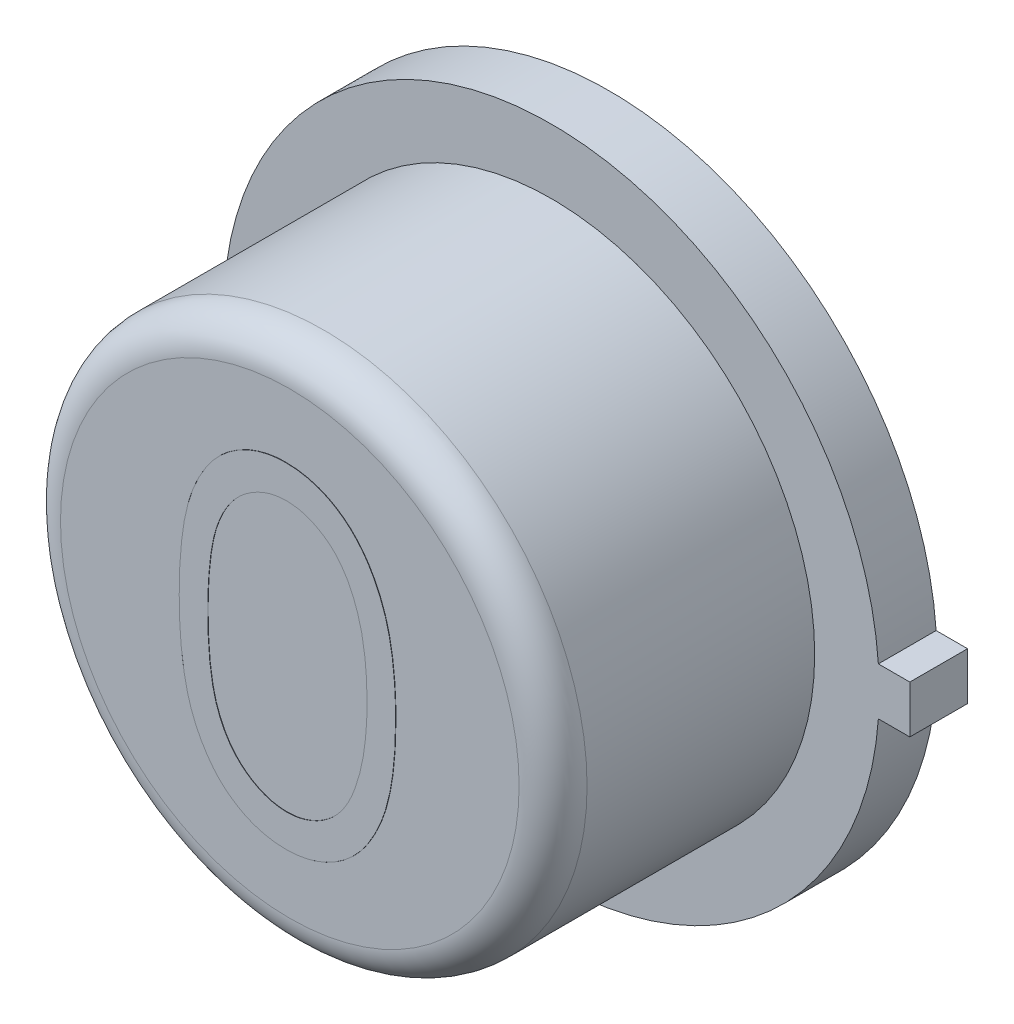
from build123d import *

# Parameters (mm, degrees)
BOSS_EXTRUDE1_DEPTH = 0.4318
SKETCH2_R           = 1.9685
BOSS_EXTRUDE2_DEPTH = 1.9558
SKETCH3_R           = 1.757566481
BOSS_EXTRUDE3_DEPTH = 0.00254
FILLET1_R           = 0.254
BOSS_EXTRUDE6_DEPTH = 0.00254


with BuildPart() as part:
    # Sketch1 → Boss-Extrude1 (new body)
    with BuildSketch(Plane.XY):
        with BuildLine():
            Line((2.6797, 0.1778), (2.4511, 0.1778))
            Line((2.4511, 0.1778), (2.44464279, 0.1778))
            ThreePointArc((2.44464279, 0.1778), (-2.4511, 0), (2.44464279, -0.1778))
            Line((2.44464279, -0.1778), (2.4511, -0.1778))
            Line((2.4511, -0.1778), (2.6797, -0.1778))
            Line((2.6797, -0.1778), (2.6797, 0.1778))
        make_face()
    extrude(amount=BOSS_EXTRUDE1_DEPTH)

    # Sketch2 → Boss-Extrude2 (add)
    with BuildSketch(Plane.XY.offset(0.4318)):
        Circle(SKETCH2_R)
    extrude(amount=BOSS_EXTRUDE2_DEPTH)

    # Sketch3 → Boss-Extrude3 (add)
    with BuildSketch(Plane(origin=(0, 0, 0), x_dir=(-1, 0, 0), z_dir=(0, 0, -1))):
        Circle(SKETCH3_R)
    extrude(amount=BOSS_EXTRUDE3_DEPTH)

    # Fillet1
    fillet1_edges = [part.edges().sort_by_distance(p)[0] for p in [
        (-1.9685, 0, 2.3876),
    ]]
    fillet(fillet1_edges, radius=FILLET1_R)

    # Sketch4 → Boss-Extrude6 (add)
    with BuildSketch(Plane.XY.offset(2.3876)):
        with BuildLine():
            add(Edge.make_bspline(
                [(-0.824278846, -0.028470233), (-0.824055677, 0.009696025), (-0.823622167, 0.083834532), (-0.818799509, 0.191864798), (-0.810788071, 0.293210994), (-0.799808894, 0.387877973), (-0.786448054, 0.475890174), (-0.76861216, 0.557012392), (-0.748328807, 0.631620089), (-0.724820804, 0.699956554), (-0.698295183, 0.762942456), (-0.66942473, 0.821742459), (-0.637063683, 0.876267595), (-0.603061533, 0.927388127), (-0.566041892, 0.974267248), (-0.52705825, 1.017566988), (-0.484589081, 1.056286624), (-0.44007807, 1.091560626), (-0.393122225, 1.122482499), (-0.345059983, 1.149719058), (-0.295560527, 1.172987182), (-0.244488713, 1.191282282), (-0.19230358, 1.206393591), (-0.138822701, 1.2167275), (-0.083957773, 1.22322961), (-0.046924957, 1.223851231), (-0.02814378, 1.224166485)],
                knots=[0, 0, 0, 0, 0.000114492, 0.000222403, 0.000324329, 0.000419413, 0.000508267, 0.000591258, 0.000668447, 0.000740102, 0.000807875, 0.000873367, 0.000936443, 0.000997963, 0.001057413, 0.001115492, 0.001172544, 0.00122961, 0.001285706, 0.001341027, 0.001395232, 0.001449558, 0.001503614, 0.00155806, 0.001612792, 0.001669112, 0.001669112, 0.001669112, 0.001669112], degree=3))
            add(Edge.make_bspline(
                [(-0.02814378, 1.224166485), (-0.009205713, 1.223834597), (0.028456143, 1.223174575), (0.084136826, 1.216830964), (0.138531164, 1.206305075), (0.191407254, 1.191390983), (0.243199433, 1.17288821), (0.293502596, 1.149696797), (0.342629199, 1.122700996), (0.389798556, 1.090980108), (0.435528499, 1.055613595), (0.478695774, 1.015633994), (0.519304309, 0.971444988), (0.557863758, 0.923519363), (0.593280156, 0.870937904), (0.627007794, 0.814615143), (0.657196626, 0.753566108), (0.686271467, 0.688809397), (0.711367792, 0.618553229), (0.73400072, 0.543193633), (0.752288018, 0.461840481), (0.76752072, 0.374920607), (0.779321443, 0.282114802), (0.787916152, 0.183622005), (0.792456233, 0.079377418), (0.793311238, 0.008104667), (0.79375, -0.028470233)],
                knots=[0, 0, 0, 0, 5.6797e-05, 0.000112951, 0.000167865, 0.00022284, 0.000277613, 0.000332685, 0.000388839, 0.000445596, 0.000503038, 0.000562112, 0.000621861, 0.000682948, 0.000746456, 0.000811902, 0.00087974, 0.000950647, 0.001024738, 0.00110337, 0.001186569, 0.001274717, 0.001368023, 0.001467137, 0.001571235, 0.001680965, 0.001680965, 0.001680965, 0.001680965], degree=3))
            add(Edge.make_bspline(
                [(0.79375, -0.028470233), (0.79330669, -0.064885606), (0.792442918, -0.135839476), (0.787967048, -0.239615014), (0.779150551, -0.337585112), (0.768121969, -0.42998473), (0.752847296, -0.516429288), (0.734065924, -0.597217922), (0.713212758, -0.672699514), (0.687471586, -0.742255698), (0.659297513, -0.806856781), (0.628643889, -0.867182109), (0.595803168, -0.92376489), (0.560024039, -0.976152218), (0.521887699, -1.024715197), (0.480577918, -1.068596615), (0.437259181, -1.108853805), (0.391394662, -1.144675715), (0.34348966, -1.176029841), (0.294531788, -1.204069979), (0.243652379, -1.22668008), (0.192004459, -1.246094099), (0.138849268, -1.260926192), (0.084253062, -1.271181798), (0.028493552, -1.27837443), (-0.009199299, -1.278923125), (-0.02814378, -1.279198899)],
                knots=[0, 0, 0, 0, 0.000109253, 0.000212874, 0.000311514, 0.000404286, 0.000491965, 0.000574698, 0.000653064, 0.000726706, 0.000796984, 0.000864397, 0.000929602, 0.000993109, 0.00105457, 0.001114643, 0.001173717, 0.001231829, 0.001288983, 0.00134537, 0.001400876, 0.001455813, 0.001510787, 0.00156617, 0.001622379, 0.001679176, 0.001679176, 0.001679176, 0.001679176], degree=3))
            add(Edge.make_bspline(
                [(-0.02814378, -1.279198899), (-0.046924436, -1.278881611), (-0.083956224, -1.27825598), (-0.138828678, -1.271783245), (-0.192088698, -1.26137684), (-0.2439991, -1.246805901), (-0.294826211, -1.22897045), (-0.343877435, -1.205733747), (-0.391698162, -1.178972532), (-0.43816081, -1.148495647), (-0.482392298, -1.113578574), (-0.524641528, -1.074958584), (-0.563847121, -1.031671942), (-0.600337461, -0.984402141), (-0.635018046, -0.93358406), (-0.666919566, -0.878523863), (-0.696427237, -0.819439873), (-0.723398969, -0.755950366), (-0.747312613, -0.687128888), (-0.768436143, -0.612188108), (-0.785114525, -0.530466577), (-0.799390429, -0.442620654), (-0.810905054, -0.348272855), (-0.818766121, -0.247371959), (-0.823624766, -0.139980844), (-0.824056841, -0.066318729), (-0.824278846, -0.028470233)],
                knots=[0, 0, 0, 0, 5.632e-05, 0.000111052, 0.000165498, 0.000218966, 0.000272681, 0.000326886, 0.000381558, 0.000436992, 0.000493389, 0.000550441, 0.000608519, 0.000668346, 0.000729471, 0.000792958, 0.00085909, 0.000927487, 0.00099975, 0.001077526, 0.001160884, 0.001249813, 0.001344479, 0.001445931, 0.001553365, 0.001666903, 0.001666903, 0.001666903, 0.001666903], degree=3))
        make_face()
        with BuildLine():
            add(Edge.make_bspline(
                [(-0.610576923, -0.027516207), (-0.610495656, -0.059322018), (-0.610337934, -0.121050852), (-0.606217554, -0.210751356), (-0.60060445, -0.294415098), (-0.593364568, -0.372148308), (-0.582612919, -0.44368787), (-0.570565979, -0.509525815), (-0.555905582, -0.569313721), (-0.538559865, -0.623461856), (-0.518802908, -0.672889169), (-0.497231597, -0.718882139), (-0.474058141, -0.761984081), (-0.448123505, -0.80180784), (-0.419878435, -0.838483283), (-0.389960914, -0.87265955), (-0.357254388, -0.903137496), (-0.312008092, -0.939690945), (-0.252275133, -0.977463785), (-0.177013716, -1.010356392), (-0.099678574, -1.031027313), (-0.04718817, -1.033656047), (-0.020988582, -1.03496813)],
                knots=[0, 0, 0, 0, 9.5407e-05, 0.000185167, 0.000269316, 0.000346968, 0.000419286, 0.000486272, 0.000547705, 0.000603822, 0.000656704, 0.000707279, 0.00075616, 0.000803394, 0.000849667, 0.000894946, 0.00093949, 0.000983592, 0.001069348, 0.001150525, 0.001229313, 0.001307828, 0.001307828, 0.001307828, 0.001307828], degree=3))
            add(Edge.make_bspline(
                [(-0.020988582, -1.03496813), (0.005380477, -1.033881068), (0.058064152, -1.03170919), (0.135035538, -1.010755049), (0.209759347, -0.979139166), (0.268319006, -0.941755238), (0.312870522, -0.906153285), (0.344790832, -0.87579939), (0.374088404, -0.841811559), (0.401875601, -0.805140788), (0.427361151, -0.765086473), (0.45053625, -0.721841221), (0.471684027, -0.675284941), (0.483732503, -0.642784458), (0.489892578, -0.626167799)],
                knots=[0, 0, 0, 0, 7.8951e-05, 0.000157739, 0.000237661, 0.000321698, 0.00036513, 0.000408653, 0.000453617, 0.000499601, 0.000546577, 0.000595878, 0.000646686, 0.000699838, 0.000699838, 0.000699838, 0.000699838], degree=3))
            add(Edge.make_bspline(
                [(0.489892578, -0.626167799), (0.497071549, -0.604920423), (0.511647938, -0.561779137), (0.530433806, -0.494856724), (0.545228443, -0.424641986), (0.558538519, -0.351554541), (0.567623366, -0.275055387), (0.574935717, -0.195381222), (0.579242845, -0.112471974), (0.579776756, -0.05614181), (0.580048077, -0.027516207)],
                knots=[0, 0, 0, 0, 6.7277e-05, 0.000136602, 0.000208365, 0.000282476, 0.000359392, 0.000439374, 0.000522485, 0.00060836, 0.00060836, 0.00060836, 0.00060836], degree=3))
            add(Edge.make_bspline(
                [(0.580048077, -0.027516207), (0.579673752, 0.001104767), (0.578941492, 0.057093509), (0.576142511, 0.139088914), (0.568914686, 0.216967873), (0.560887071, 0.291065891), (0.549050748, 0.360972793), (0.53628874, 0.427273804), (0.519142915, 0.489147541), (0.500827854, 0.547562721), (0.479865781, 0.601855666), (0.456790969, 0.65227951), (0.432147237, 0.699077689), (0.405380462, 0.742121804), (0.376808399, 0.781604659), (0.345676924, 0.816734625), (0.313220913, 0.84860049), (0.267761364, 0.884974131), (0.208247606, 0.922061553), (0.134193692, 0.956192186), (0.0571292, 0.975792113), (0.005031904, 0.978555511), (-0.020988582, 0.979935716)],
                knots=[0, 0, 0, 0, 8.5874e-05, 0.000167988, 0.000246028, 0.000320462, 0.000391511, 0.00045868, 0.0005229, 0.000583997, 0.000642286, 0.000697358, 0.000750279, 0.000800842, 0.00084931, 0.000896293, 0.000941496, 0.000985598, 0.001070697, 0.001151193, 0.001229402, 0.001307441, 0.001307441, 0.001307441, 0.001307441], degree=3))
            add(Edge.make_bspline(
                [(-0.020988582, 0.979935716), (-0.04732561, 0.978553607), (-0.100047645, 0.975786871), (-0.177913128, 0.956265211), (-0.252551268, 0.922238532), (-0.311907649, 0.884851293), (-0.357398903, 0.849242549), (-0.38943195, 0.818363551), (-0.419467114, 0.784586367), (-0.447135674, 0.747573635), (-0.47304999, 0.707796305), (-0.496849572, 0.664941449), (-0.518292612, 0.618791896), (-0.538080484, 0.569386785), (-0.555479113, 0.515243322), (-0.569830542, 0.45552906), (-0.583088697, 0.389900523), (-0.592474407, 0.3179735), (-0.600818141, 0.240220821), (-0.606180272, 0.156348217), (-0.610351717, 0.066497272), (-0.610500351, 0.004449274), (-0.610576923, -0.027516207)],
                knots=[0, 0, 0, 0, 7.899e-05, 0.000158124, 0.000239056, 0.000324154, 0.000367959, 0.000412157, 0.000457436, 0.00050342, 0.000550654, 0.000599765, 0.00065034, 0.000703222, 0.000759339, 0.000820772, 0.00088738, 0.000960102, 0.001038277, 0.00112195, 0.001212187, 0.001308071, 0.001308071, 0.001308071, 0.001308071], degree=3))
        make_face(mode=Mode.SUBTRACT)
    extrude(amount=BOSS_EXTRUDE6_DEPTH)


solid = part.part
